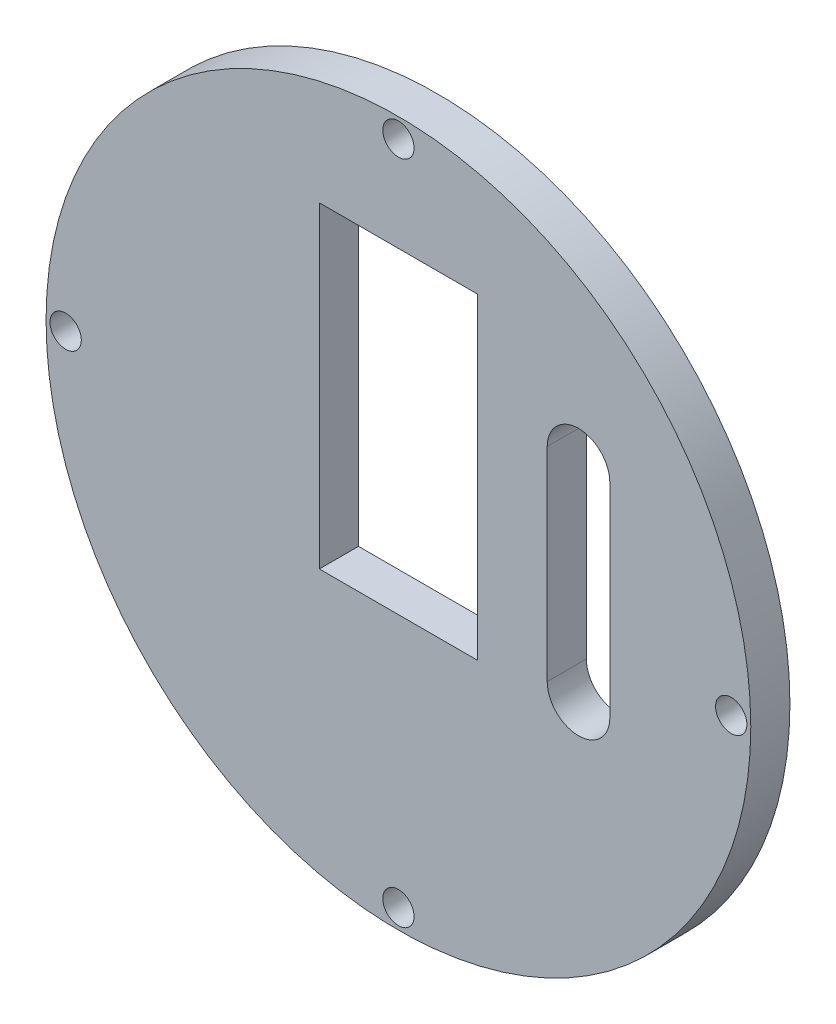
from build123d import *

# Parameters (mm, degrees)
SKETCH1_R           = 45
SKETCH1_R_2         = 2
SKETCH1_W           = 20.2
SKETCH1_H           = 40.5
BOSS_EXTRUDE1_DEPTH = 5
CUT_EXTRUDE1_DEPTH  = 10


with BuildPart() as part:
    # Sketch1 → Boss-Extrude1 (new body)
    with BuildSketch(Plane.XY):
        Circle(SKETCH1_R)
        with Locations((42.5, 0)):
            Circle(SKETCH1_R_2, mode=Mode.SUBTRACT)
        with Locations((0, -42.5)):
            Circle(SKETCH1_R_2, mode=Mode.SUBTRACT)
        with Locations((-42.5, 0)):
            Circle(SKETCH1_R_2, mode=Mode.SUBTRACT)
        with Locations((0, 42.5)):
            Circle(SKETCH1_R_2, mode=Mode.SUBTRACT)
        with Locations((0, 10.15)):
            Rectangle(SKETCH1_W, SKETCH1_H, mode=Mode.SUBTRACT)
    extrude(amount=BOSS_EXTRUDE1_DEPTH)

    # Sketch2 → Cut-Extrude1 (cut)
    with BuildSketch(Plane(origin=(0, 0, 0), x_dir=(-1, 0, 0), z_dir=(0, 0, -1))):
        with BuildLine():
            Line((-19, 18), (-19, -8))
            ThreePointArc((-19, -8), (-23, -12), (-27, -8))
            Line((-27, -8), (-27, 18))
            ThreePointArc((-27, 18), (-23, 22), (-19, 18))
        make_face()
    extrude(amount=-CUT_EXTRUDE1_DEPTH, mode=Mode.SUBTRACT)


solid = part.part
